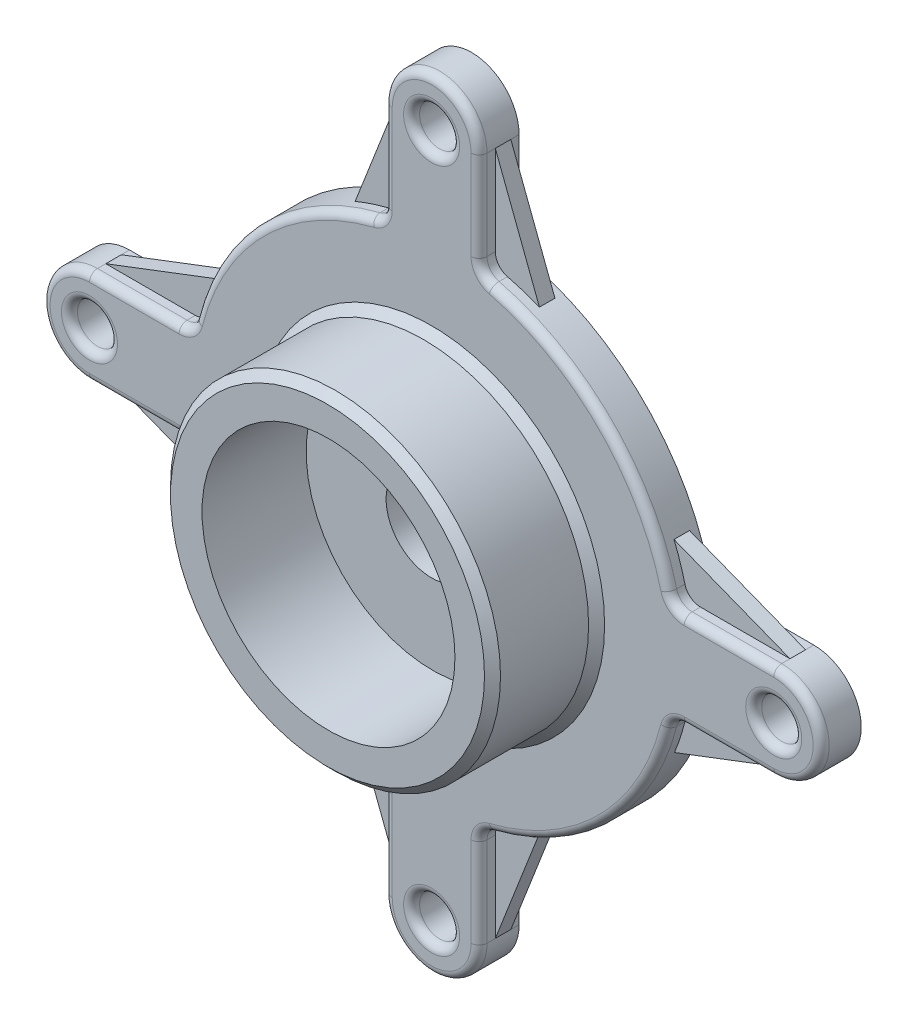
from build123d import *

# Parameters (mm, degrees)
SKETCH1_R          = 6.35
EXTRUDE1_DEPTH     = 12.7
SKETCH3_R          = 52.327921125
SKETCH3_R_2        = 40.111407582
EXTRUDE3_DEPTH     = 33.02
CHAMFER1_SIZE      = 2.54
CHAMFER2_SIZE      = 2.54
SKETCH6_R          = 52.327921125
EXTRUDE4_DEPTH     = 17.78
SKETCH7_R          = 35.56
CUT_EXTRUDE2_DEPTH = 10.16
SKETCH5_R          = 14.433715845
CUT_EXTRUDE1_DEPTH = 189.047450874
CHAMFER3_SIZE      = 2.54
FILLET1_R          = 2.54
RIB1_REACH         = 181.378
SKETCH8_WALL_W     = 400.24651193
SKETCH8_WALL_H     = 4.92
CIRPATTERN1_COUNT  = 4
RIB2_REACH         = 181.378
SKETCH9_WALL_W     = 399.965882856
SKETCH9_WALL_H     = 4.92
CIRPATTERN2_COUNT  = 4


with BuildPart() as part:
    # Sketch1 → Extrude1 (new body)
    with BuildSketch(Plane.XY):
        with BuildLine():
            Line((-108.499268261, 15.041974925), (-80.102582468, 15.041974925))
            ThreePointArc((-80.102582468, 15.041974925), (-76.978554283, 16.116123218), (-75.175655839, 18.884318272))
            ThreePointArc((-75.175655839, 18.884318272), (-54.808743405, 54.808743405), (-18.884318272, 75.175655839))
            ThreePointArc((-18.884318272, 75.175655839), (-16.116123218, 76.978554283), (-15.041974925, 80.102582468))
            Line((-15.041974925, 80.102582468), (-15.041974925, 108.499268261))
            ThreePointArc((-15.041974925, 108.499268261), (0, 123.541243186), (15.041974925, 108.499268261))
            Line((15.041974925, 108.499268261), (15.041974925, 80.102582468))
            ThreePointArc((15.041974925, 80.102582468), (16.116123218, 76.978554283), (18.884318272, 75.175655839))
            ThreePointArc((18.884318272, 75.175655839), (54.808743405, 54.808743405), (75.175655839, 18.884318272))
            ThreePointArc((75.175655839, 18.884318272), (76.978554283, 16.116123218), (80.102582468, 15.041974925))
            Line((80.102582468, 15.041974925), (108.499268261, 15.041974925))
            ThreePointArc((108.499268261, 15.041974925), (123.541243186, 0), (108.499268261, -15.041974925))
            Line((108.499268261, -15.041974925), (80.102582468, -15.041974925))
            ThreePointArc((80.102582468, -15.041974925), (76.978554283, -16.116123218), (75.175655839, -18.884318272))
            ThreePointArc((75.175655839, -18.884318272), (54.808743405, -54.808743405), (18.884318272, -75.175655839))
            ThreePointArc((18.884318272, -75.175655839), (16.116123218, -76.978554283), (15.041974925, -80.102582468))
            Line((15.041974925, -80.102582468), (15.041974925, -108.499268261))
            ThreePointArc((15.041974925, -108.499268261), (0, -123.541243186), (-15.041974925, -108.499268261))
            Line((-15.041974925, -108.499268261), (-15.041974925, -80.102582468))
            ThreePointArc((-15.041974925, -80.102582468), (-16.116123218, -76.978554283), (-18.884318272, -75.175655839))
            ThreePointArc((-18.884318272, -75.175655839), (-54.808743405, -54.808743405), (-75.175655839, -18.884318272))
            ThreePointArc((-75.175655839, -18.884318272), (-76.978554283, -16.116123218), (-80.102582468, -15.041974925))
            Line((-80.102582468, -15.041974925), (-108.499268261, -15.041974925))
            ThreePointArc((-108.499268261, -15.041974925), (-123.541243186, 0), (-108.499268261, 15.041974925))
        make_face()
        with Locations((-108.499268261, 0)):
            Circle(SKETCH1_R, mode=Mode.SUBTRACT)
        with Locations((0, 108.499268261)):
            Circle(SKETCH1_R, mode=Mode.SUBTRACT)
        with Locations((108.499268261, 0)):
            Circle(SKETCH1_R, mode=Mode.SUBTRACT)
        with Locations((0, -108.499268261)):
            Circle(SKETCH1_R, mode=Mode.SUBTRACT)
    extrude(amount=EXTRUDE1_DEPTH)

    # Sketch3 → Extrude3 (add)
    with BuildSketch(Plane(origin=(-17.13936337, 18.877140209, 12.7), x_dir=(1, 0, 0), z_dir=(0, 0, 1))):
        with Locations(Location((17.13936337, -18.877140209, 0), (0, 0, 180))):
            Circle(SKETCH3_R)
        with Locations((17.454729956, -18.424450968)):
            Circle(SKETCH3_R_2, mode=Mode.SUBTRACT)
    extrude(amount=EXTRUDE3_DEPTH)

    # Chamfer1
    chamfer1_edges = [part.edges().sort_by_distance(p)[0] for p in [
        (52.327921125, 0, 45.72),
    ]]
    chamfer(chamfer1_edges, length=CHAMFER1_SIZE)

    # Chamfer2
    chamfer2_edges = [part.edges().sort_by_distance(p)[0] for p in [
        (52.327921125, 0, 12.7),
    ]]
    chamfer(chamfer2_edges, length=CHAMFER2_SIZE)

    # Sketch6 → Extrude4 (add)
    with BuildSketch(Plane(origin=(-20.565222676, 19.927315007, 0), x_dir=(-1, 0, 0), z_dir=(0, 0, -1))):
        with Locations((-20.565222676, -19.927315007)):
            Circle(SKETCH6_R)
    extrude(amount=EXTRUDE4_DEPTH)

    # Sketch7 → Cut-Extrude2 (cut)
    with BuildSketch(Plane(origin=(-3.078400565, -13.387465701, -17.78), x_dir=(-1, 0, 0), z_dir=(0, 0, -1))):
        with Locations((-3.078400565, 13.387465701)):
            Circle(SKETCH7_R)
    extrude(amount=-CUT_EXTRUDE2_DEPTH, mode=Mode.SUBTRACT)

    # Sketch5 → Cut-Extrude1 (cut, through all)
    with BuildSketch(Plane(origin=(3.316629154, -11.286808812, 12.7), x_dir=(1, 0, 0), z_dir=(0, 0, 1))):
        with Locations((-3.316629154, 11.286808812)):
            Circle(SKETCH5_R)
    extrude(amount=-CUT_EXTRUDE1_DEPTH, mode=Mode.SUBTRACT)

    # Chamfer3
    chamfer3_edges = [part.edges().sort_by_distance(p)[0] for p in [
        (35.56, 0, -17.78),
        (52.327921125, 0, 0),
        (52.327921125, 0, -17.78),
    ]]
    chamfer(chamfer3_edges, length=CHAMFER3_SIZE)

    # Fillet1
    fillet1_edges = [part.edges().sort_by_distance(p)[0] for p in [
        (-76.978554283, 16.116123218, 12.7),
        (-94.300925364, 15.041974925, 12.7),
        (-123.541243186, 0, 12.7),
        (-94.300925364, -15.041974925, 12.7),
        (-76.978554283, -16.116123218, 12.7),
        (-54.808743405, -54.808743405, 12.7),
        (-16.116123218, -76.978554283, 12.7),
        (-15.041974925, -94.300925364, 12.7),
        (0, -123.541243186, 12.7),
        (15.041974925, -94.300925364, 12.7),
        (-16.116123218, 76.978554283, 12.7),
        (16.116123218, -76.978554283, 12.7),
        (54.808743405, -54.808743405, 12.7),
        (76.978554283, -16.116123218, 12.7),
        (94.300925364, -15.041974925, 12.7),
        (123.541243186, 0, 12.7),
        (-114.849268261, 0, 12.7),
        (94.300925364, 15.041974925, 12.7),
        (-6.35, 108.499268261, 12.7),
        (76.978554283, 16.116123218, 12.7),
        (54.808743405, 54.808743405, 12.7),
        (102.149268261, 0, 12.7),
        (16.116123218, 76.978554283, 12.7),
        (-6.35, -108.499268261, 12.7),
        (15.041974925, 94.300925364, 12.7),
        (-54.808743405, 54.808743405, 12.7),
        (0, 123.541243186, 12.7),
        (-15.041974925, 94.300925364, 12.7),
    ]]
    fillet(fillet1_edges, radius=FILLET1_R)

    # Sketch8 wall → Rib1 (add, up to next)
    with BuildSketch(Plane(origin=(-22.225757145, 90.107254317, 5.08), x_dir=(-0.36382424062, -0.931467617224, 0), z_dir=(0.931467617224, -0.36382424062, 0)), mode=Mode.PRIVATE) as rib1_sk1:
        Rectangle(SKETCH8_WALL_W, SKETCH8_WALL_H)
    rib1_tool1 = extrude(rib1_sk1.sketch, amount=RIB1_REACH, mode=Mode.PRIVATE) - part.part
    rib1 = rib1_tool1.solids().sort_by_distance((-22.225757145, 90.107254317, 5.08))[0]
    add(rib1)

    # CirPattern1: Rib1 ×4 about axis
    cirpattern1_axis = Axis((0, 0, 0), (0, 0, 1))
    for i in range(1, CIRPATTERN1_COUNT):
        add(rib1.rotate(cirpattern1_axis, i * 360 / CIRPATTERN1_COUNT))

    # Sketch9 wall → Rib2 (add, up to next)
    with BuildSketch(Plane(origin=(22.036134923, 90.184431626, 5.08), x_dir=(0.356755982247, -0.934197607111, 0), z_dir=(0.934197607111, 0.356755982247, 0)), mode=Mode.PRIVATE) as rib2_sk1:
        Rectangle(SKETCH9_WALL_W, SKETCH9_WALL_H)
    rib2_tool1 = extrude(rib2_sk1.sketch, amount=-RIB2_REACH, mode=Mode.PRIVATE) - part.part
    rib2 = rib2_tool1.solids().sort_by_distance((22.036134923, 90.184431626, 5.08))[0]
    add(rib2)

    # CirPattern2: Rib2 ×4 about axis
    cirpattern2_axis = Axis((0, 0, 0), (0, 0, 1))
    for i in range(1, CIRPATTERN2_COUNT):
        add(rib2.rotate(cirpattern2_axis, i * 360 / CIRPATTERN2_COUNT))


solid = part.part
